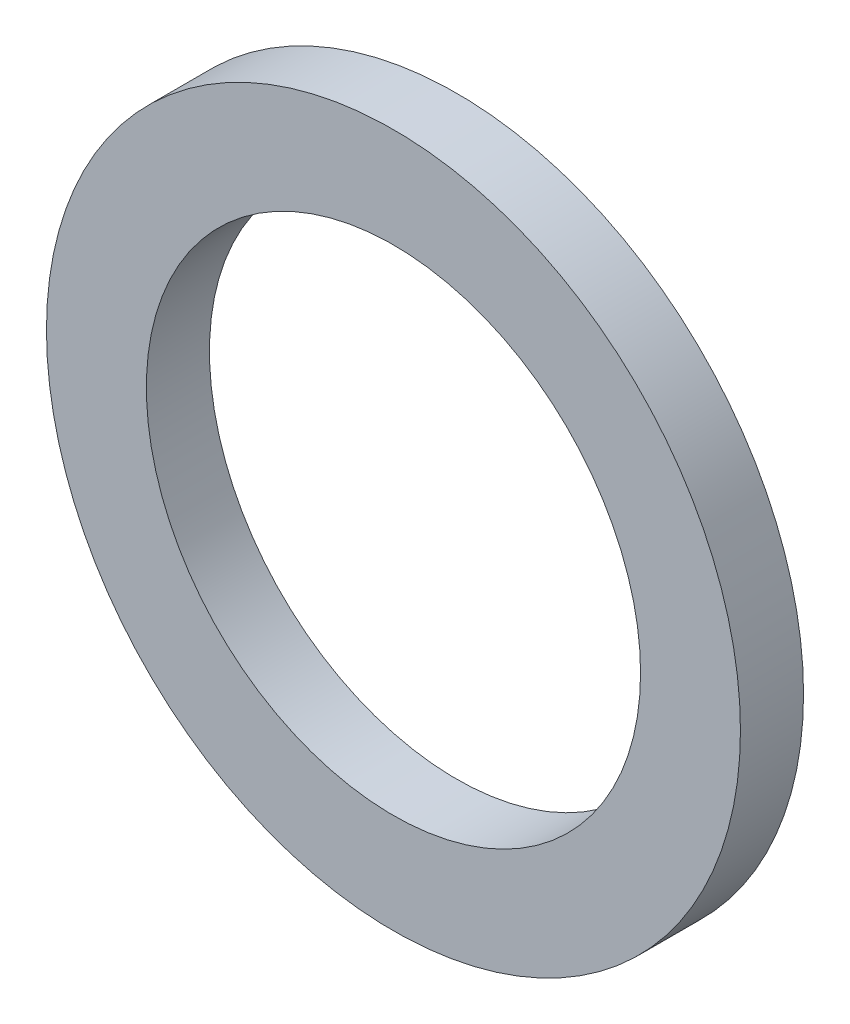
from build123d import *

# Parameters (mm, degrees)
SKETCH1_R          = 8.382
SKETCH1_R_2        = 5.969
BASE_EXTRUDE_DEPTH = 1.524


with BuildPart() as part:
    # Sketch1 → Base-Extrude (new body)
    with BuildSketch(Plane.XY):
        Circle(SKETCH1_R)
        Circle(SKETCH1_R_2, mode=Mode.SUBTRACT)
    extrude(amount=BASE_EXTRUDE_DEPTH)


solid = part.part
